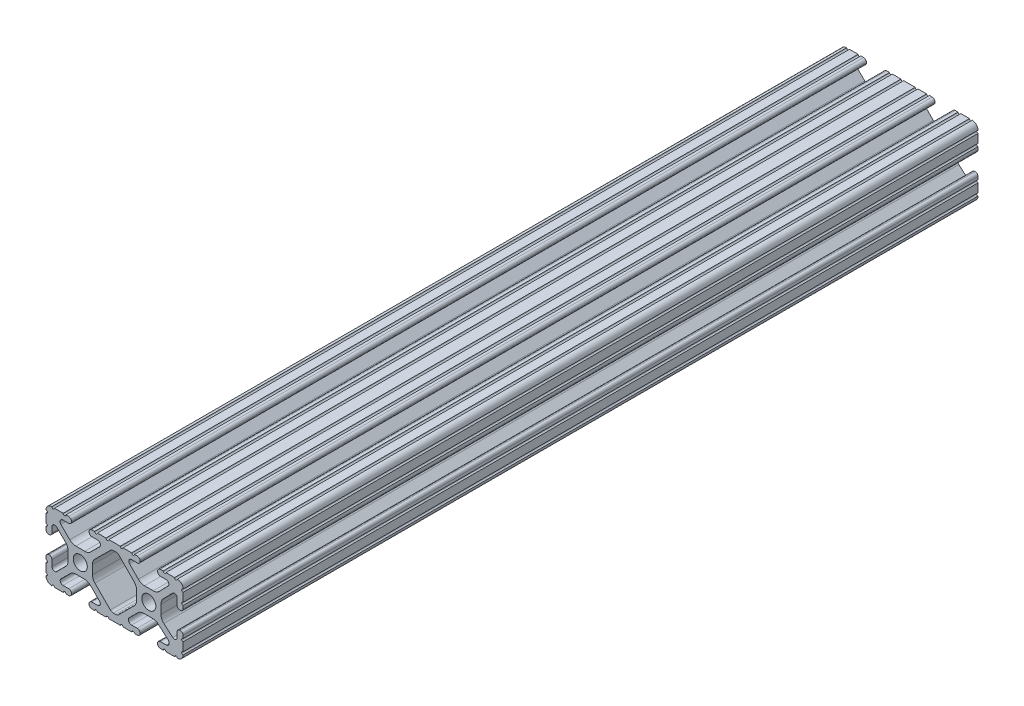
from build123d import *

# Parameters (mm, degrees)
SKETCH1_R      = 2.6035
EXTRUDE1_DEPTH = 294.6


with BuildPart() as part:
    # Sketch1 → Extrude1 (new body)
    with BuildSketch(Plane.XY):
        with BuildLine():
            Line((22.2504, 12.7), (19.03310265, 12.7))
            ThreePointArc((19.03310265, 12.7), (18.52510265, 12.192), (18.01710265, 12.7))
            Line((18.01710265, 12.7), (16.98745015, 12.7))
            ThreePointArc((16.98745015, 12.7), (16.245730386, 12.392769614), (15.9385, 11.65104985))
            Line((15.9385, 11.65104985), (15.9385, 11.53922))
            ThreePointArc((15.9385, 11.53922), (16.245750844, 10.797450844), (16.98752, 10.4902))
            Line((16.98752, 10.4902), (19.116384363, 10.4902))
            ThreePointArc((19.116384363, 10.4902), (20.052502933, 9.869096983), (19.844087081, 8.765172272))
            Line((19.844087081, 8.765172272), (16.618993479, 5.455112286))
            ThreePointArc((16.618993479, 5.455112286), (15.578994274, 4.745442459), (14.344932584, 4.4958))
            Line((14.344932584, 4.4958), (11.083317835, 4.4958))
            ThreePointArc((11.083317835, 4.4958), (9.854330953, 4.743306833), (8.816955189, 5.447238587))
            Line((8.816955189, 5.447238587), (5.564154119, 8.762652677))
            ThreePointArc((5.564154119, 8.762652677), (5.352591412, 9.867473037), (6.289393385, 10.4902))
            Line((6.289393385, 10.4902), (8.41248, 10.4902))
            ThreePointArc((8.41248, 10.4902), (9.154249156, 10.797450844), (9.4615, 11.53922))
            Line((9.4615, 11.53922), (9.4615, 11.65104985))
            ThreePointArc((9.4615, 11.65104985), (9.154269614, 12.392769614), (8.41254985, 12.7))
            Line((8.41254985, 12.7), (7.38288465, 12.7))
            ThreePointArc((7.38288465, 12.7), (6.87488465, 12.192), (6.36688465, 12.7))
            Line((6.36688465, 12.7), (3.14958095, 12.7))
            ThreePointArc((3.14958095, 12.7), (2.64158095, 12.192), (2.13358095, 12.7))
            Line((2.13358095, 12.7), (-2.13358095, 12.7))
            ThreePointArc((-2.13358095, 12.7), (-2.64158095, 12.192), (-3.14958095, 12.7))
            Line((-3.14958095, 12.7), (-6.36689735, 12.7))
            ThreePointArc((-6.36689735, 12.7), (-6.87489735, 12.192), (-7.38289735, 12.7))
            Line((-7.38289735, 12.7), (-8.41254985, 12.7))
            ThreePointArc((-8.41254985, 12.7), (-9.154269614, 12.392769614), (-9.4615, 11.65104985))
            Line((-9.4615, 11.65104985), (-9.4615, 11.53922))
            ThreePointArc((-9.4615, 11.53922), (-9.154249156, 10.797450844), (-8.41248, 10.4902))
            Line((-8.41248, 10.4902), (-6.283641037, 10.4902))
            ThreePointArc((-6.283641037, 10.4902), (-5.297291557, 9.829633109), (-5.532576693, 8.666071843))
            Line((-5.532576693, 8.666071843), (-8.809985098, 5.416263103))
            ThreePointArc((-8.809985098, 5.416263103), (-9.836720513, 4.734920264), (-11.045536121, 4.4958))
            Line((-11.045536121, 4.4958), (-14.354463879, 4.4958))
            ThreePointArc((-14.354463879, 4.4958), (-15.563279487, 4.734920264), (-16.590014902, 5.416263103))
            Line((-16.590014902, 5.416263103), (-19.867423307, 8.666071843))
            ThreePointArc((-19.867423307, 8.666071843), (-20.102708443, 9.829633109), (-19.116358963, 10.4902))
            Line((-19.116358963, 10.4902), (-16.98752, 10.4902))
            ThreePointArc((-16.98752, 10.4902), (-16.245750844, 10.797450844), (-15.9385, 11.53922))
            Line((-15.9385, 11.53922), (-15.9385, 11.65104985))
            ThreePointArc((-15.9385, 11.65104985), (-16.245730386, 12.392769614), (-16.98745015, 12.7))
            Line((-16.98745015, 12.7), (-18.01711535, 12.7))
            ThreePointArc((-18.01711535, 12.7), (-18.52511535, 12.192), (-19.03311535, 12.7))
            Line((-19.03311535, 12.7), (-22.2504, 12.7))
            ThreePointArc((-22.2504, 12.7), (-22.758323491, 12.192000006), (-23.266399977, 12.699846982))
            ThreePointArc((-23.266399977, 12.699846982), (-24.782522516, 12.082522516), (-25.399846982, 10.566399977))
            ThreePointArc((-25.399846982, 10.566399977), (-24.892000006, 10.058323491), (-25.4, 9.5504))
            Line((-25.4, 9.5504), (-25.4, 6.3330836))
            ThreePointArc((-25.4, 6.3330836), (-24.892, 5.8250836), (-25.4, 5.3170836))
            Line((-25.4, 5.3170836), (-25.4, 4.237520184))
            ThreePointArc((-25.4, 4.237520184), (-25.107393763, 3.531106237), (-24.400979816, 3.2385))
            Line((-24.400979816, 3.2385), (-24.23922, 3.2385))
            ThreePointArc((-24.23922, 3.2385), (-23.497450844, 3.545750844), (-23.1902, 4.28752))
            Line((-23.1902, 4.28752), (-23.1902, 6.334741132))
            ThreePointArc((-23.1902, 6.334741132), (-22.556026952, 7.286023527), (-21.434002553, 7.066535717))
            Line((-21.434002553, 7.066535717), (-18.147950853, 3.808156468))
            ThreePointArc((-18.147950853, 3.808156468), (-17.452759693, 2.774838327), (-17.208501877, 1.553619571))
            Line((-17.208501877, 1.553619571), (-17.208501877, -1.695179196))
            ThreePointArc((-17.208501877, -1.695179196), (-17.450738657, -2.911536421), (-18.140486065, -3.942289578))
            Line((-18.140486065, -3.942289578), (-21.431579576, -7.227386226))
            ThreePointArc((-21.431579576, -7.227386226), (-22.55444896, -7.449940594), (-23.1902, -6.498002195))
            Line((-23.1902, -6.498002195), (-23.1902, -4.28752))
            ThreePointArc((-23.1902, -4.28752), (-23.497450844, -3.545750844), (-24.23922, -3.2385))
            Line((-24.23922, -3.2385), (-24.35098, -3.2385))
            ThreePointArc((-24.35098, -3.2385), (-25.092749156, -3.545750844), (-25.4, -4.28752))
            Line((-25.4, -4.28752), (-25.4, -5.3171344))
            ThreePointArc((-25.4, -5.3171344), (-24.892, -5.8251344), (-25.4, -6.3331344))
            Line((-25.4, -6.3331344), (-25.4, -9.5504))
            ThreePointArc((-25.4, -9.5504), (-24.892000006, -10.058323491), (-25.399846982, -10.566399977))
            ThreePointArc((-25.399846982, -10.566399977), (-24.782522516, -12.082522516), (-23.266399977, -12.699846982))
            ThreePointArc((-23.266399977, -12.699846982), (-22.758323491, -12.192000006), (-22.2504, -12.7))
            Line((-22.2504, -12.7), (-19.03308995, -12.7))
            ThreePointArc((-19.03308995, -12.7), (-18.52508995, -12.192), (-18.01708995, -12.7))
            Line((-18.01708995, -12.7), (-16.9874692, -12.7))
            ThreePointArc((-16.9874692, -12.7), (-16.245700044, -12.392749156), (-15.9384492, -11.65098))
            Line((-15.9384492, -11.65098), (-15.9384492, -11.53922))
            ThreePointArc((-15.9384492, -11.53922), (-16.245700044, -10.797450844), (-16.9874692, -10.4902))
            Line((-16.9874692, -10.4902), (-19.116358963, -10.4902))
            ThreePointArc((-19.116358963, -10.4902), (-20.055197748, -9.862578342), (-19.834124023, -8.755124678))
            Line((-19.834124023, -8.755124678), (-16.49660751, -5.423689618))
            ThreePointArc((-16.49660751, -5.423689618), (-15.467274017, -4.736928798), (-14.253591699, -4.4958))
            Line((-14.253591699, -4.4958), (-11.146408301, -4.4958))
            ThreePointArc((-11.146408301, -4.4958), (-9.932725983, -4.736928798), (-8.90339249, -5.423689618))
            Line((-8.90339249, -5.423689618), (-5.565875977, -8.755124678))
            ThreePointArc((-5.565875977, -8.755124678), (-5.344802252, -9.862578342), (-6.283641037, -10.4902))
            Line((-6.283641037, -10.4902), (-8.4125308, -10.4902))
            ThreePointArc((-8.4125308, -10.4902), (-9.154299956, -10.797450844), (-9.4615508, -11.53922))
            Line((-9.4615508, -11.53922), (-9.4615508, -11.65098))
            ThreePointArc((-9.4615508, -11.65098), (-9.154299956, -12.392749156), (-8.4125308, -12.7))
            Line((-8.4125308, -12.7), (-7.38287195, -12.7))
            ThreePointArc((-7.38287195, -12.7), (-6.87487195, -12.192), (-6.36687195, -12.7))
            Line((-6.36687195, -12.7), (-3.14960635, -12.7))
            ThreePointArc((-3.14960635, -12.7), (-2.64160635, -12.192), (-2.13360635, -12.7))
            Line((-2.13360635, -12.7), (2.13360635, -12.7))
            ThreePointArc((2.13360635, -12.7), (2.64159365, -12.1920127), (3.14958095, -12.7))
            Line((3.14958095, -12.7), (6.36691005, -12.7))
            ThreePointArc((6.36691005, -12.7), (6.87491005, -12.192), (7.38291005, -12.7))
            Line((7.38291005, -12.7), (8.4125308, -12.7))
            ThreePointArc((8.4125308, -12.7), (9.154299956, -12.392749156), (9.4615508, -11.65098))
            Line((9.4615508, -11.65098), (9.4615508, -11.53922))
            ThreePointArc((9.4615508, -11.53922), (9.154299956, -10.797450844), (8.4125308, -10.4902))
            Line((8.4125308, -10.4902), (6.289393385, -10.4902))
            ThreePointArc((6.289393385, -10.4902), (5.231590322, -9.783049717), (5.480677245, -8.535265862))
            Line((5.480677245, -8.535265862), (8.597933595, -5.423689618))
            ThreePointArc((8.597933595, -5.423689618), (9.627267088, -4.736928798), (10.840949406, -4.4958))
            Line((10.840949406, -4.4958), (14.102564155, -4.4958))
            ThreePointArc((14.102564155, -4.4958), (15.215927525, -4.697410182), (16.187895372, -5.276636531))
            Line((16.187895372, -5.276636531), (19.868247549, -8.482246082))
            ThreePointArc((19.868247549, -8.482246082), (20.188435806, -9.746879864), (19.116384363, -10.4902))
            Line((19.116384363, -10.4902), (16.9874692, -10.4902))
            ThreePointArc((16.9874692, -10.4902), (16.245700044, -10.797450844), (15.9384492, -11.53922))
            Line((15.9384492, -11.53922), (15.9384492, -11.65098))
            ThreePointArc((15.9384492, -11.65098), (16.245700044, -12.392749156), (16.9874692, -12.7))
            Line((16.9874692, -12.7), (18.01710265, -12.7))
            ThreePointArc((18.01710265, -12.7), (18.52510265, -12.192), (19.03310265, -12.7))
            Line((19.03310265, -12.7), (22.2504, -12.7))
            ThreePointArc((22.2504, -12.7), (22.758323491, -12.192000006), (23.266399977, -12.699846982))
            ThreePointArc((23.266399977, -12.699846982), (24.782522516, -12.082522516), (25.399846982, -10.566399977))
            ThreePointArc((25.399846982, -10.566399977), (24.892000006, -10.058323492), (25.4, -9.550400001))
            Line((25.4, -9.550400001), (25.4, -6.333083592))
            ThreePointArc((25.4, -6.333083592), (24.892000001, -5.825083593), (25.4, -5.317083593))
            Line((25.4, -5.317083593), (25.4, -4.237520184))
            ThreePointArc((25.4, -4.237520184), (25.107393763, -3.531106237), (24.400979816, -3.2385))
            Line((24.400979816, -3.2385), (24.189220184, -3.2385))
            ThreePointArc((24.189220184, -3.2385), (23.482806237, -3.531106237), (23.1902, -4.237520184))
            Line((23.1902, -4.237520184), (23.1902, -6.155876159))
            ThreePointArc((23.1902, -6.155876159), (22.62232736, -7.038258539), (21.583974541, -6.886926384))
            Line((21.583974541, -6.886926384), (18.29817066, -4.024970844))
            ThreePointArc((18.29817066, -4.024970844), (17.493730985, -2.946044689), (17.208501877, -1.630807374))
            Line((17.208501877, -1.630807374), (17.208501877, 1.630807374))
            ThreePointArc((17.208501877, 1.630807374), (17.442348332, 2.82673414), (18.109440981, 3.846495088))
            Line((18.109440981, 3.846495088), (21.526346532, 7.353420386))
            ThreePointArc((21.526346532, 7.353420386), (22.585896263, 7.574939077), (23.1902, 6.676867167))
            Line((23.1902, 6.676867167), (23.1902, 4.237520184))
            ThreePointArc((23.1902, 4.237520184), (23.482806237, 3.531106237), (24.189220184, 3.2385))
            Line((24.189220184, 3.2385), (24.400979816, 3.2385))
            ThreePointArc((24.400979816, 3.2385), (25.107393763, 3.531106237), (25.4, 4.237520184))
            Line((25.4, 4.237520184), (25.4, 5.3170836))
            ThreePointArc((25.4, 5.3170836), (24.891949193, 5.825134407), (25.4, 6.333185215))
            Line((25.4, 6.333185215), (25.4, 9.550400015))
            ThreePointArc((25.4, 9.550400015), (24.892000013, 10.058323498), (25.399846982, 10.566399977))
            ThreePointArc((25.399846982, 10.566399977), (24.782522516, 12.082522516), (23.266399977, 12.699846982))
            ThreePointArc((23.266399977, 12.699846982), (22.758323491, 12.192000006), (22.2504, 12.7))
        make_face()
        with Locations((-12.7, 0)):
            Circle(SKETCH1_R, mode=Mode.SUBTRACT)
        with Locations((12.7, 0)):
            Circle(SKETCH1_R, mode=Mode.SUBTRACT)
        with BuildLine():
            Line((-7.259513935, -3.869413038), (-1.545748891, -9.572766749))
            ThreePointArc((-1.545748891, -9.572766749), (-1.035199478, -9.913400116), (-0.433213048, -10.033))
            Line((-0.433213048, -10.033), (0.433213048, -10.033))
            ThreePointArc((0.433213048, -10.033), (1.035199478, -9.913400116), (1.545748891, -9.572766749))
            Line((1.545748891, -9.572766749), (7.259513935, -3.869413038))
            ThreePointArc((7.259513935, -3.869413038), (7.949261343, -2.838659881), (8.191498123, -1.622302656))
            Line((8.191498123, -1.622302656), (8.191498123, 1.622302656))
            ThreePointArc((8.191498123, 1.622302656), (7.955573352, 2.823327967), (7.282860769, 3.845864069))
            Line((7.282860769, 3.845864069), (1.675572808, 9.561086461))
            ThreePointArc((1.675572808, 9.561086461), (1.161034429, 9.910236611), (0.551456936, 10.033))
            Line((0.551456936, 10.033), (-0.395199982, 10.033))
            ThreePointArc((-0.395199982, 10.033), (-0.994772524, 9.914396349), (-1.50403329, 9.576450301))
            Line((-1.50403329, 9.576450301), (-7.252049147, 3.876839553))
            ThreePointArc((-7.252049147, 3.876839553), (-7.947240307, 2.843521412), (-8.191498123, 1.622302656))
            Line((-8.191498123, 1.622302656), (-8.191498123, -1.622302656))
            ThreePointArc((-8.191498123, -1.622302656), (-7.949261343, -2.838659881), (-7.259513935, -3.869413038))
        make_face(mode=Mode.SUBTRACT)
    extrude(amount=-EXTRUDE1_DEPTH)


solid = part.part
